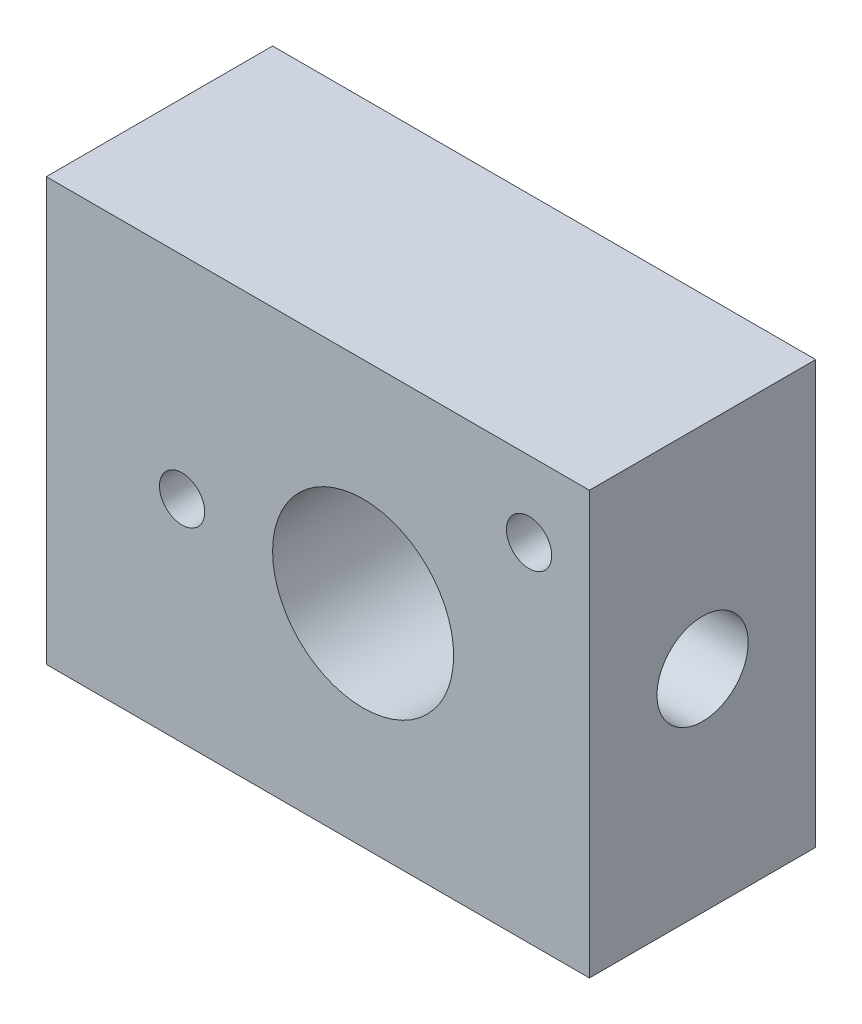
from build123d import *

# Parameters (mm, degrees)
IZIM1_W                     = 36
IZIM1_H                     = 28
Y_KSEKLIK_EKSTR_ZYON1_DEPTH = 15
IZIM3_R                     = 6
IZIM3_R_2                   = 1.5
KES_EKSTR_ZYON1_DEPTH       = 16
KES_EKSTR_ZYON2_REACH       = 38
IZIM4_R                     = 3.022097143


with BuildPart() as part:
    # Çizim1 → Yükseklik-Ekstrüzyon1 (new body)
    with BuildSketch(Plane.XY):
        Rectangle(IZIM1_W, IZIM1_H)
    extrude(amount=Y_KSEKLIK_EKSTR_ZYON1_DEPTH)

    # Çizim3 → Kes-Ekstrüzyon1 (cut, through all)
    with BuildSketch(Plane.XY.offset(15)):
        with Locations((3, 0)):
            Circle(IZIM3_R)
        with Locations((-9, 0)):
            Circle(IZIM3_R_2)
        with Locations((14, 9)):
            Circle(IZIM3_R_2)
    extrude(amount=-KES_EKSTR_ZYON1_DEPTH, mode=Mode.SUBTRACT)

    # Çizim4 → Kes-Ekstrüzyon2 (cut, up to next)
    with BuildSketch(Plane(origin=(18, 0, 0), x_dir=(0, 0, -1), z_dir=(1, 0, 0)), mode=Mode.PRIVATE) as kes_ekstr_zyon2_sk1:
        with Locations((-7.5, 0)):
            Circle(IZIM4_R)
    kes_ekstr_zyon2_tool1 = extrude(kes_ekstr_zyon2_sk1.sketch, amount=-KES_EKSTR_ZYON2_REACH, mode=Mode.PRIVATE) & part.part
    add(kes_ekstr_zyon2_tool1.solids().sort_by_distance((18, 0, 7.5))[0], mode=Mode.SUBTRACT)


solid = part.part
